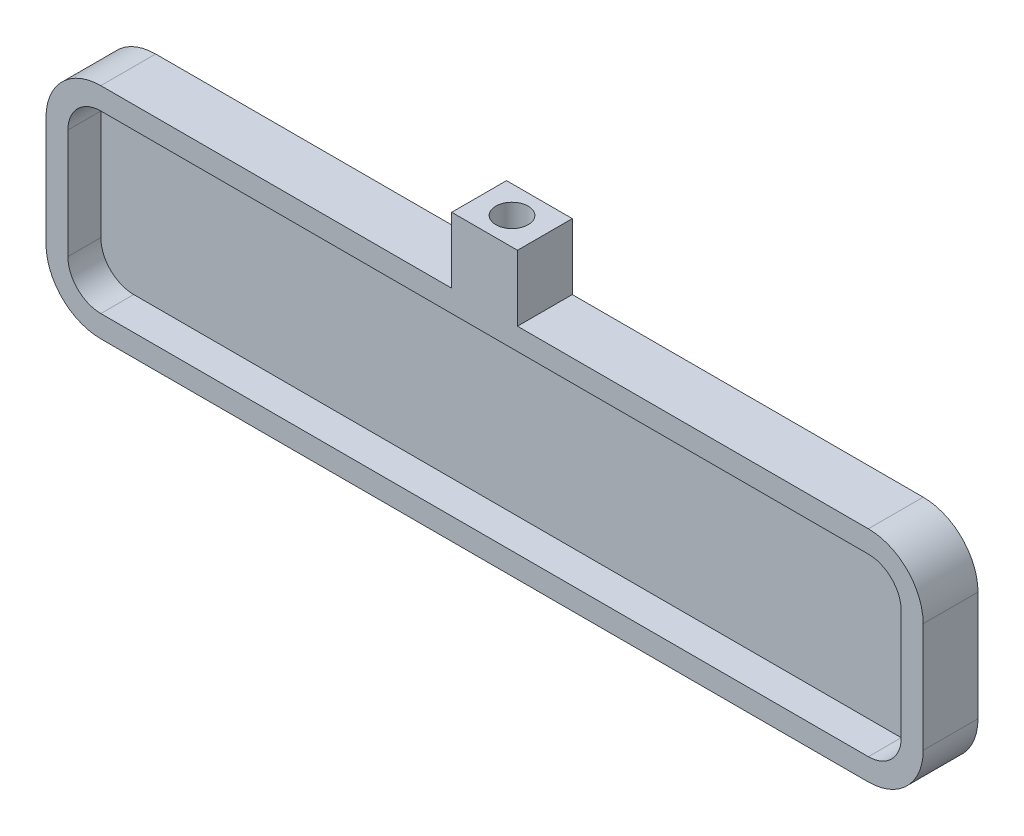
from build123d import *

# Parameters (mm, degrees)
SKETCH1_W           = 80
SKETCH1_H           = 20
BOSS_EXTRUDE1_DEPTH = 5
FILLET1_R           = 5
SHELL1_T            = -2
BOSS_EXTRUDE2_DEPTH = 6
SKETCH3_R           = 1.475
CUT_EXTRUDE1_DEPTH  = 4


with BuildPart() as part:
    # Sketch1 → Boss-Extrude1 (new body)
    with BuildSketch(Plane.XY):
        Rectangle(SKETCH1_W, SKETCH1_H)
    extrude(amount=BOSS_EXTRUDE1_DEPTH)

    # Fillet1
    fillet1_edges = [part.edges().sort_by_distance(p)[0] for p in [
        (40, -10, 2.5),
        (-40, -10, 2.5),
        (-40, 10, 2.5),
        (40, 10, 2.5),
    ]]
    fillet(fillet1_edges, radius=FILLET1_R)

    # Shell1
    shell1_openings = [part.faces().sort_by_distance(p)[0] for p in [
        (0, 0, 5),
    ]]
    offset(amount=SHELL1_T, openings=shell1_openings, kind=Kind.INTERSECTION)

    # Sketch2 → Boss-Extrude2 (add)
    with BuildSketch(Plane(origin=(0, 10, 0), x_dir=(1, 0, 0), z_dir=(0, 1, 0))):
        Polygon((0, 0), (-3, 0), (-3, -5), (3, -5), (3, 0), align=None)
    extrude(amount=BOSS_EXTRUDE2_DEPTH)

    # Sketch3 → Cut-Extrude1 (cut)
    with BuildSketch(Plane(origin=(0, 16, 0), x_dir=(1, 0, 0), z_dir=(0, 1, 0))):
        with Locations((0, -2.5)):
            Circle(SKETCH3_R)
    extrude(amount=-CUT_EXTRUDE1_DEPTH, mode=Mode.SUBTRACT)


solid = part.part
